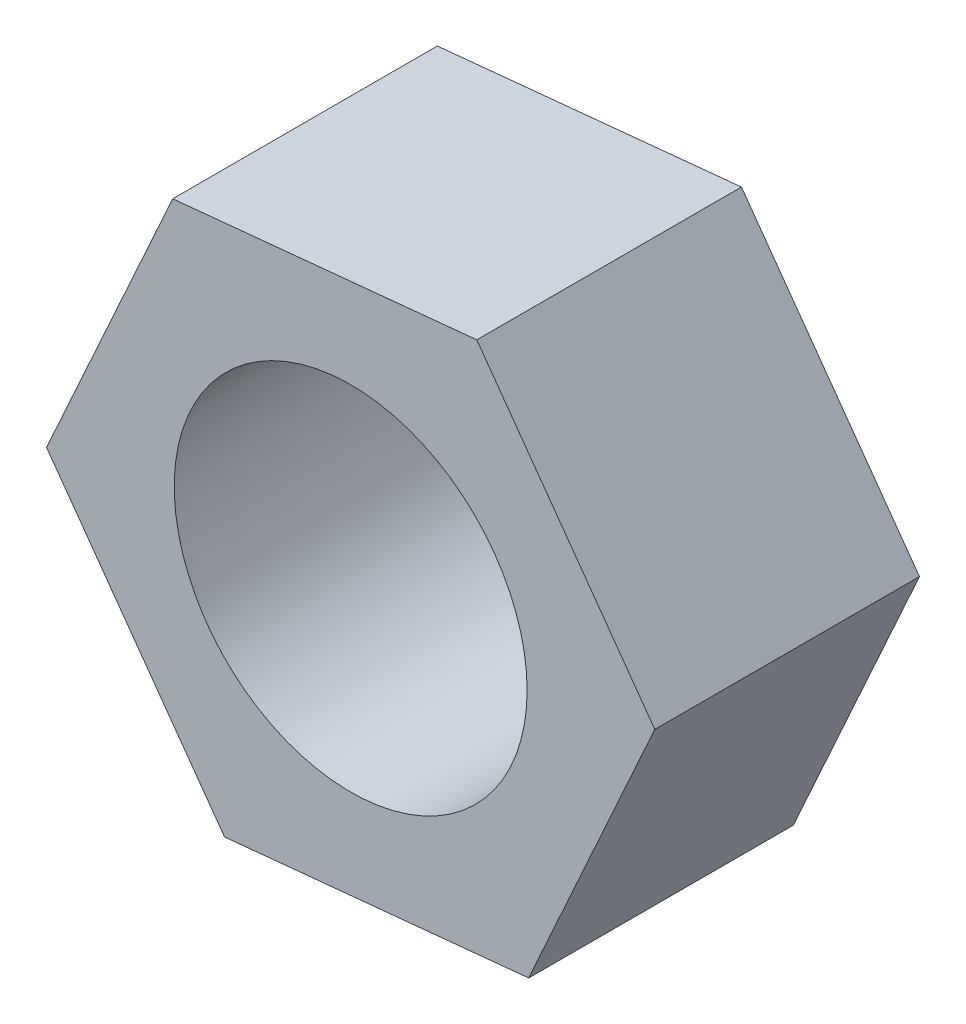
from build123d import *

# Parameters (mm, degrees)
IZIM1_R                     = 10
Y_KSEKLIK_EKSTR_ZYON1_DEPTH = 15


with BuildPart() as part:
    # Çizim1 → Yükseklik-Ekstrüzyon1 (new body)
    with BuildSketch(Plane.XY):
        Polygon((10.087696673, -14.079715048), (17.237239246, 1.696344061), (7.149542573, 15.776059109), (-10.087696673, 14.079715048), (-17.237239246, -1.696344061), (-7.149542573, -15.776059109), align=None)
        Circle(IZIM1_R, mode=Mode.SUBTRACT)
    extrude(amount=Y_KSEKLIK_EKSTR_ZYON1_DEPTH)


solid = part.part
